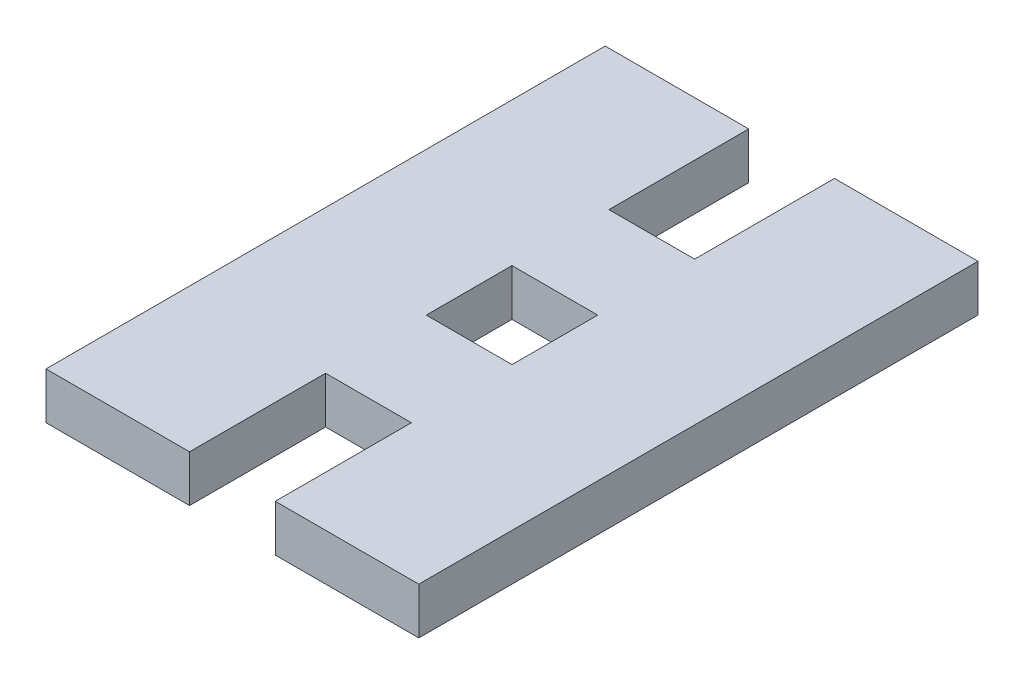
from build123d import *

# Parameters (mm, degrees)
SKETCH1_W           = 5.842
SKETCH1_H           = 5.842
BOSS_EXTRUDE1_DEPTH = 3.175


with BuildPart() as part:
    # Sketch1 → Boss-Extrude1 (new body)
    with BuildSketch(Plane(origin=(0, 0, 0), x_dir=(1, 0, 0), z_dir=(0, 1, 0))):
        Polygon((9.779, 38.1), (0, 38.1), (0, 0), (9.779, 0), (9.779, 9.271), (15.621, 9.271), (15.621, 0), (25.4, 0), (25.4, 38.1), (15.621, 38.1), (15.621, 28.575), (9.779, 28.575), align=None)
        with Locations((12.7, 19.05)):
            Rectangle(SKETCH1_W, SKETCH1_H, mode=Mode.SUBTRACT)
    extrude(amount=BOSS_EXTRUDE1_DEPTH)


solid = part.part
